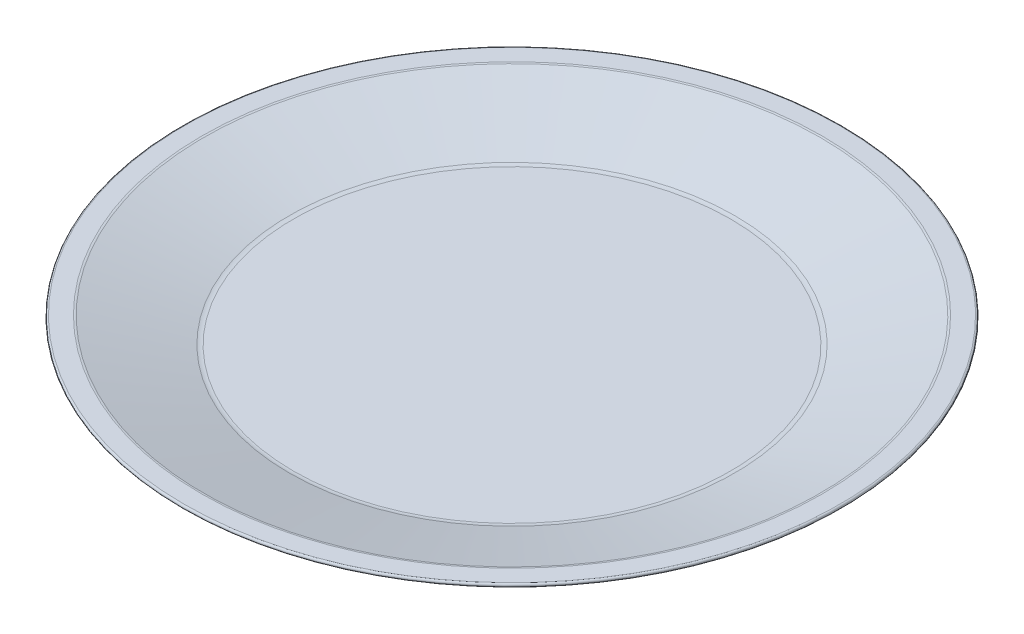
from build123d import *


with BuildPart() as part:
    # ProfileS → Profile (revolve)
    with BuildSketch(Plane.XY):
        with BuildLine():
            Line((0, 0), (62.971191448, 0))
            ThreePointArc((62.971191448, 0), (63.969190528, 0.071508257), (64.946799558, 0.284572047))
            Line((64.946799558, 0.284572047), (94.641114865, 9.020326575))
            ThreePointArc((94.641114865, 9.020326575), (94.994892267, 9.571285649), (94.5, 10))
            Line((94.5, 10), (89.401244899, 10))
            ThreePointArc((89.401244899, 10), (89.116102305, 9.979569069), (88.836785439, 9.918693701))
            Line((88.836785439, 9.918693701), (64.241225233, 2.682939173))
            ThreePointArc((64.241225233, 2.682939173), (63.612762285, 2.545969594), (62.971191448, 2.5))
            Line((62.971191448, 2.5), (0, 2.5))
            Line((0, 2.5), (0, 0))
        make_face()
    revolve(axis=Axis((0, 0, 0), (0, 1, 0)))


solid = part.part
